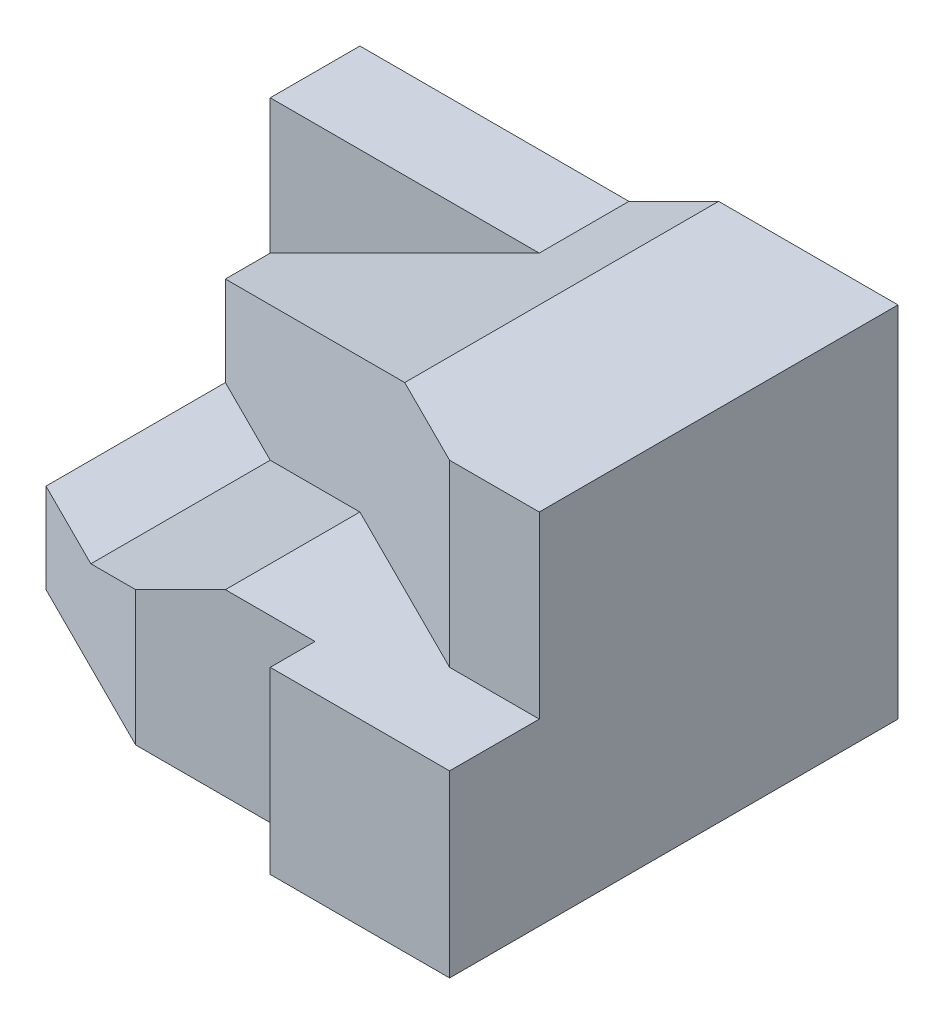
from build123d import *

# Parameters (mm, degrees)
SKETCH1_W            = 120
SKETCH1_H            = 100
BOSS_EXTRUDE1_DEPTH  = 20
CUT_EXTRUDE1_DEPTH   = 20
SKETCH3_W            = 40
SKETCH3_H            = 40
BOSS_EXTRUDE3_DEPTH  = 100
BOSS_EXTRUDE4_DEPTH  = 90
SKETCH5_W            = 20
SKETCH5_H            = 40
BOSS_EXTRUDE6_DEPTH  = 80
BOSS_EXTRUDE7_DEPTH  = 80
SKETCH7_W            = 60
SKETCH7_H            = 50
BOSS_EXTRUDE8_DEPTH  = 20
SKETCH8_W            = 10
SKETCH8_H            = 20
BOSS_EXTRUDE9_DEPTH  = 10
BOSS_EXTRUDE10_DEPTH = 42
BOSS_EXTRUDE18_DEPTH = 42
BOSS_EXTRUDE19_DEPTH = 30
BOSS_EXTRUDE21_DEPTH = 30
BOSS_EXTRUDE22_DEPTH = 30
BOSS_EXTRUDE23_DEPTH = 30
BOSS_EXTRUDE24_DEPTH = 30
SKETCH22_W           = 120
SKETCH22_H           = 100
CUT_EXTRUDE3_DEPTH   = 30


with BuildPart() as part:
    # Sketch1 → Boss-Extrude1 (new body)
    with BuildSketch(Plane(origin=(0, 0, 0), x_dir=(1, 0, 0), z_dir=(0, 1, 0))):
        with Locations((60, 50)):
            Rectangle(SKETCH1_W, SKETCH1_H)
    extrude(amount=BOSS_EXTRUDE1_DEPTH)

    # Sketch2 → Cut-Extrude1 (cut)
    with BuildSketch(Plane(origin=(0, 20, 0), x_dir=(1, 0, 0), z_dir=(0, 1, 0))):
        Polygon((0, 30), (40, 10), (80, 10), (80, 0), (0, 0), align=None)
    extrude(amount=-CUT_EXTRUDE1_DEPTH, mode=Mode.SUBTRACT)

    # Sketch3 → Boss-Extrude3 (add)
    with BuildSketch(Plane.XY):
        with Locations((100, 20)):
            Rectangle(SKETCH3_W, SKETCH3_H)
    extrude(amount=-BOSS_EXTRUDE3_DEPTH)

    # Sketch4 → Boss-Extrude4 (add)
    with BuildSketch(Plane.XY.offset(-10)):
        Polygon((80, 20), (80, 40), (60, 40), (40, 30), (40, 20), align=None)
    extrude(amount=-BOSS_EXTRUDE4_DEPTH)

    # Sketch5 → Boss-Extrude6 (add)
    with BuildSketch(Plane.XY.offset(-20)):
        with Locations((110, 60)):
            Rectangle(SKETCH5_W, SKETCH5_H)
    extrude(amount=-BOSS_EXTRUDE6_DEPTH)

    # Sketch6 → Boss-Extrude7 (add)
    with BuildSketch(Plane(origin=(0, 80, 0), x_dir=(1, 0, 0), z_dir=(0, 1, 0))):
        Polygon((100, 100), (80, 100), (80, 30), (100, 20), align=None)
    extrude(amount=-BOSS_EXTRUDE7_DEPTH)

    # Sketch7 → Boss-Extrude8 (add)
    with BuildSketch(Plane(origin=(0, 0, -100), x_dir=(-1, 0, 0), z_dir=(0, 0, -1))):
        with Locations((-30, 45)):
            Rectangle(SKETCH7_W, SKETCH7_H)
    extrude(amount=-BOSS_EXTRUDE8_DEPTH)

    # Sketch8 → Boss-Extrude9 (add)
    with BuildSketch(Plane.XY.offset(-80)):
        with Locations((5, 30)):
            Rectangle(SKETCH8_W, SKETCH8_H)
    extrude(amount=BOSS_EXTRUDE9_DEPTH)

    # Sketch9 → Boss-Extrude10 (add)
    with BuildSketch(Plane(origin=(-16, 32, 0), x_dir=(-0.894427191, -0.447213595, 0), z_dir=(0.447213595, -0.894427191, 0))):
        Polygon((-107.33126292, 100), (-107.33126292, 30), (-17.88854382, 70), (-17.88854382, 80), align=None)
    extrude(amount=BOSS_EXTRUDE10_DEPTH)

    # Sketch11 → Boss-Extrude18 (add)
    with BuildSketch(Plane(origin=(0, 0, -100), x_dir=(-1, 0, 0), z_dir=(0, 0, -1))):
        Polygon((-80, 40), (-60, 40), (-60, 70), (-80, 80), align=None)
    extrude(amount=-BOSS_EXTRUDE18_DEPTH)

    # Sketch12 → Boss-Extrude19 (add)
    with BuildSketch(Plane(origin=(28, 0, -56), x_dir=(0.894427191, 0, 0.447213595), z_dir=(-0.447213595, 0, 0.894427191))):
        Polygon((58.137767415, 80), (58.137767415, 40), (-31.304951685, 20), (-31.304951685, 40), align=None)
    extrude(amount=-BOSS_EXTRUDE19_DEPTH)

    # Sketch17 → Boss-Extrude21 (add)
    with BuildSketch(Plane(origin=(28, 0, -56), x_dir=(0.894427191, 0, 0.447213595), z_dir=(-0.447213595, 0, 0.894427191))):
        Polygon((13.416407865, 30), (-31.304951685, 20), (13.416407865, 20), align=None)
    extrude(amount=-BOSS_EXTRUDE21_DEPTH)

    # Sketch19 → Boss-Extrude22 (add)
    with BuildSketch(Plane(origin=(-4, 8, 0), x_dir=(0.894427191, 0.447213595, 0), z_dir=(-0.447213595, 0.894427191, 0))):
        Polygon((26.83281573, 20), (71.55417528, 10), (71.55417528, 40), (26.83281573, 60), align=None)
    extrude(amount=-BOSS_EXTRUDE22_DEPTH)

    # Sketch20 → Boss-Extrude23 (add)
    with BuildSketch(Plane(origin=(-4, 8, 0), x_dir=(0.894427191, 0.447213595, 0), z_dir=(-0.447213595, 0.894427191, 0))):
        Polygon((49.193495505, 10), (26.83281573, 20), (49.193495505, 15), align=None)
    extrude(amount=-BOSS_EXTRUDE23_DEPTH)

    # Sketch21 → Boss-Extrude24 (add)
    with BuildSketch(Plane(origin=(12, 0, -24), x_dir=(0.894427191, 0, 0.447213595), z_dir=(-0.447213595, 0, 0.894427191))):
        Polygon((8.94427191, 20), (31.304951685, 30), (31.304951685, 20), align=None)
    extrude(amount=-BOSS_EXTRUDE24_DEPTH)

    # Sketch22 → Cut-Extrude3 (cut)
    with BuildSketch(Plane.XZ):
        with Locations((60, -50)):
            Rectangle(SKETCH22_W, SKETCH22_H)
    extrude(amount=CUT_EXTRUDE3_DEPTH, mode=Mode.SUBTRACT)


solid = part.part
